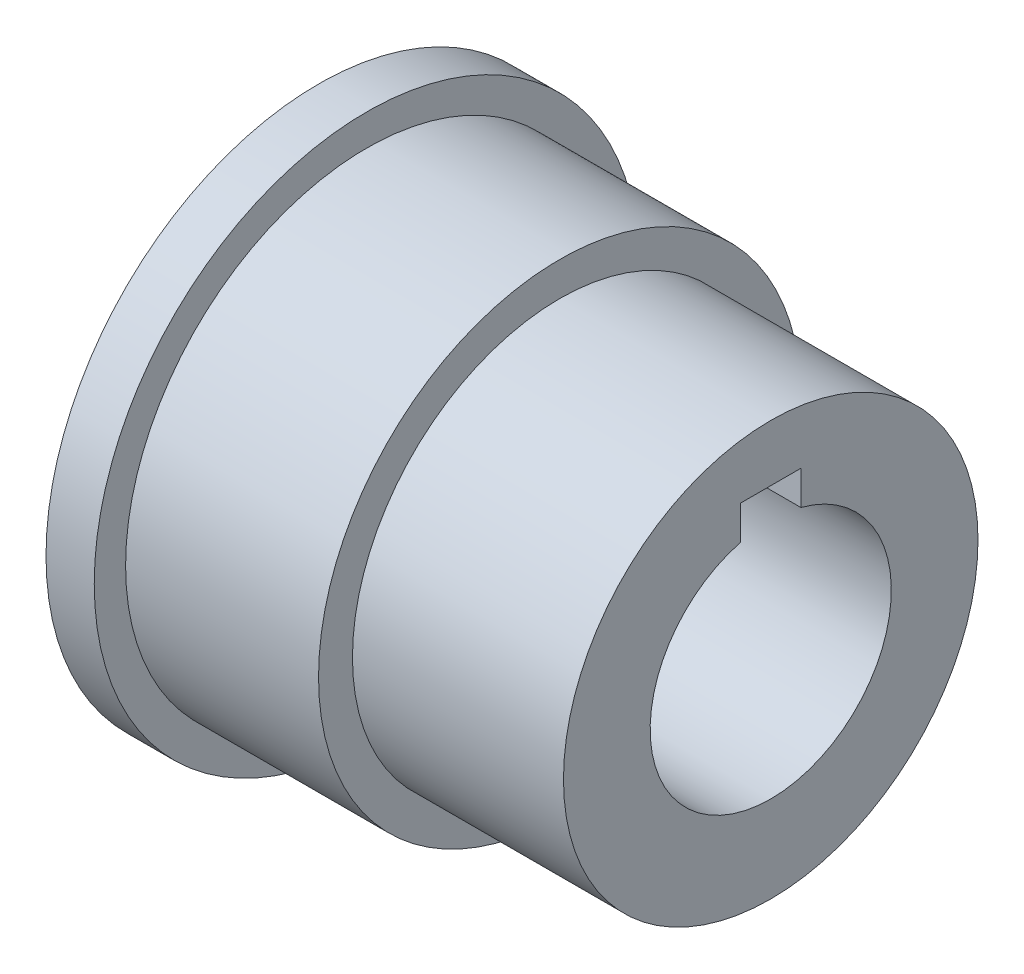
from build123d import *

# Parameters (mm, degrees)
SKETCH1_R           = 10.9140625
BOSS_EXTRUDE1_DEPTH = 23.8125
SKETCH2_R           = 12.7
SKETCH2_R_2         = 10.9140625
BOSS_EXTRUDE2_DEPTH = 12.7
SKETCH5_R           = 14.351
SKETCH5_R_2         = 12.7
BOSS_EXTRUDE3_DEPTH = 2.54


with BuildPart() as part:
    # Sketch1 → Boss-Extrude1 (new body)
    with BuildSketch(Plane(origin=(0, 0, 0), x_dir=(0, 0, -1), z_dir=(1, 0, 0))):
        Circle(SKETCH1_R)
        with BuildLine():
            Line((-1.5875, 6.148361062), (-1.5875, 7.9375))
            Line((-1.5875, 7.9375), (1.5875, 7.9375))
            Line((1.5875, 7.9375), (1.5875, 6.148361062))
            ThreePointArc((1.5875, 6.148361062), (5.020115786, 3.888564967), (6.35, 0))
            ThreePointArc((6.35, 0), (-3.888564967, -5.020115786), (-1.5875, 6.148361062))
        make_face(mode=Mode.SUBTRACT)
    extrude(amount=BOSS_EXTRUDE1_DEPTH)

    # Sketch2 → Boss-Extrude2 (add)
    with BuildSketch(Plane.ZY):
        Circle(SKETCH2_R)
        Circle(SKETCH2_R_2, mode=Mode.SUBTRACT)
    extrude(amount=-BOSS_EXTRUDE2_DEPTH)

    # Sketch5 → Boss-Extrude3 (add)
    with BuildSketch(Plane.ZY):
        Circle(SKETCH5_R)
        Circle(SKETCH5_R_2, mode=Mode.SUBTRACT)
    extrude(amount=-BOSS_EXTRUDE3_DEPTH)


solid = part.part
